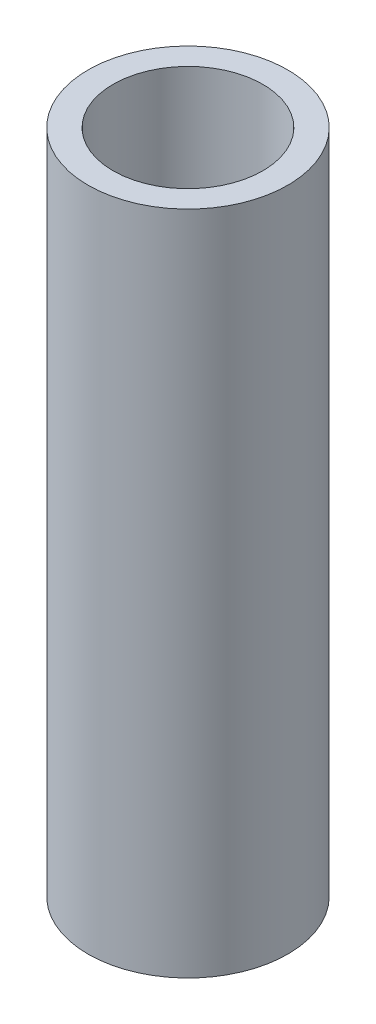
from build123d import *

# Parameters (mm, degrees)
SKETCH1_R           = 6
BOSS_EXTRUDE1_DEPTH = 40
SKETCH2_R           = 4.5
CUT_EXTRUDE1_DEPTH  = 38


with BuildPart() as part:
    # Sketch1 → Boss-Extrude1 (new body)
    with BuildSketch(Plane(origin=(0, 0, 0), x_dir=(1, 0, 0), z_dir=(0, 1, 0))):
        Circle(SKETCH1_R)
    extrude(amount=BOSS_EXTRUDE1_DEPTH)

    # Sketch2 → Cut-Extrude1 (cut)
    with BuildSketch(Plane(origin=(0, 40, 0), x_dir=(1, 0, 0), z_dir=(0, 1, 0))):
        Circle(SKETCH2_R)
    extrude(amount=-CUT_EXTRUDE1_DEPTH, mode=Mode.SUBTRACT)


solid = part.part
